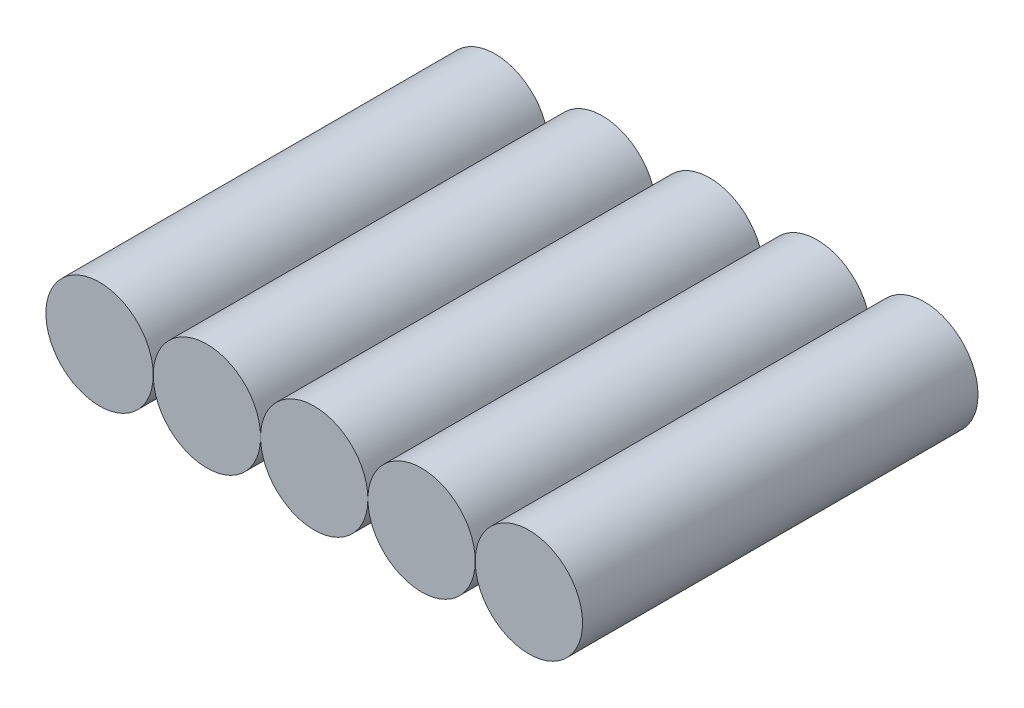
from build123d import *

# Parameters (mm, degrees)
BOSS_EXTRUDE1_DEPTH        = 35
BOSS_EXTRUDE1_DEPTH_BACK   = 35
BOSS_EXTRUDE1_2_DEPTH      = 35
BOSS_EXTRUDE1_2_DEPTH_BACK = 35
SKETCH1_R                  = 9.5
BOSS_EXTRUDE1_3_DEPTH      = 35
BOSS_EXTRUDE1_3_DEPTH_BACK = 35
BOSS_EXTRUDE1_4_DEPTH      = 35
BOSS_EXTRUDE1_4_DEPTH_BACK = 35
BOSS_EXTRUDE1_5_DEPTH      = 35
BOSS_EXTRUDE1_5_DEPTH_BACK = 35


with BuildPart() as part:
    # Sketch1 → Boss-Extrude1 (new, two sides: drawn at the far end of the back side and taken through both)
    with BuildSketch(Plane.XY.offset(-BOSS_EXTRUDE1_DEPTH_BACK)):
        with BuildLine():
            ThreePointArc((-9.5, 0), (0, -9.5), (9.5, 0))
            ThreePointArc((9.5, 0), (0, 9.5), (-9.5, 0))
        make_face()
    extrude(amount=BOSS_EXTRUDE1_DEPTH + BOSS_EXTRUDE1_DEPTH_BACK)


with BuildPart() as body_2:
    # Sketch1 → Boss-Extrude1 2 (new, two sides: drawn at the far end of the back side and taken through both)
    with BuildSketch(Plane.XY.offset(-BOSS_EXTRUDE1_2_DEPTH_BACK)):
        with Locations((-38, 0)):
            Circle(SKETCH1_R)
    extrude(amount=BOSS_EXTRUDE1_2_DEPTH + BOSS_EXTRUDE1_2_DEPTH_BACK)


with BuildPart() as body_3:
    # Sketch1 → Boss-Extrude1 3 (new, two sides: drawn at the far end of the back side and taken through both)
    with BuildSketch(Plane.XY.offset(-BOSS_EXTRUDE1_3_DEPTH_BACK)):
        with BuildLine():
            ThreePointArc((-28.5, 0), (-19, -9.5), (-9.5, 0))
            ThreePointArc((-9.5, 0), (-19, 9.5), (-28.5, 0))
        make_face()
    extrude(amount=BOSS_EXTRUDE1_3_DEPTH + BOSS_EXTRUDE1_3_DEPTH_BACK)


with BuildPart() as body_4:
    # Sketch1 → Boss-Extrude1 4 (new, two sides: drawn at the far end of the back side and taken through both)
    with BuildSketch(Plane.XY.offset(-BOSS_EXTRUDE1_4_DEPTH_BACK)):
        with Locations((38, 0)):
            Circle(SKETCH1_R)
    extrude(amount=BOSS_EXTRUDE1_4_DEPTH + BOSS_EXTRUDE1_4_DEPTH_BACK)


with BuildPart() as body_5:
    # Sketch1 → Boss-Extrude1 5 (new, two sides: drawn at the far end of the back side and taken through both)
    with BuildSketch(Plane.XY.offset(-BOSS_EXTRUDE1_5_DEPTH_BACK)):
        with BuildLine():
            ThreePointArc((28.5, 0), (19, 9.5), (9.5, 0))
            ThreePointArc((9.5, 0), (19, -9.5), (28.5, 0))
        make_face()
    extrude(amount=BOSS_EXTRUDE1_5_DEPTH + BOSS_EXTRUDE1_5_DEPTH_BACK)


solid = Compound([part.part, body_2.part, body_3.part, body_4.part, body_5.part])
